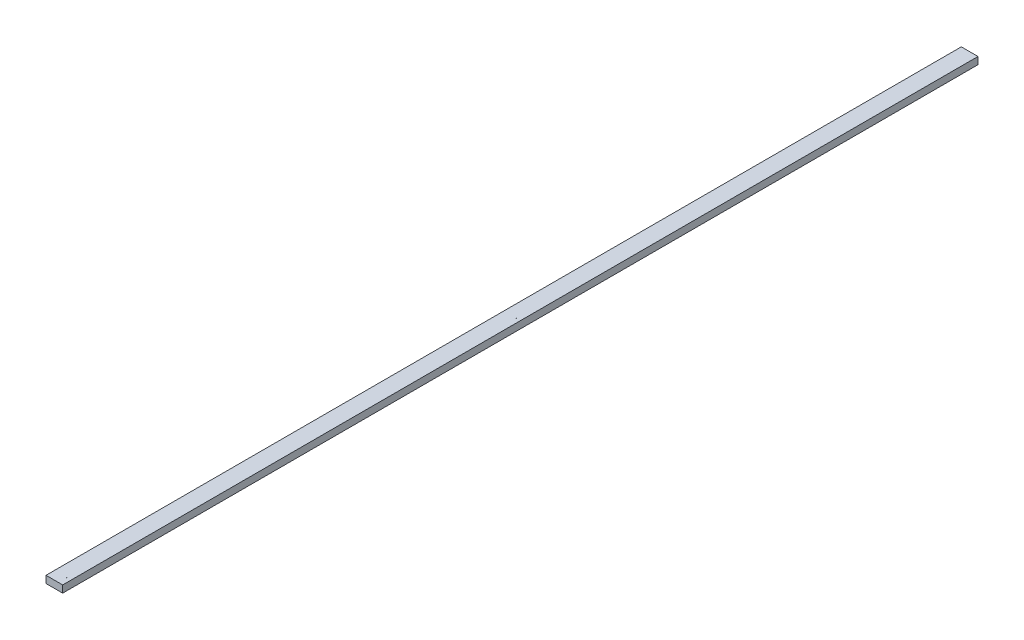
from build123d import *

# Parameters (mm, degrees)
SKETCH1_W           = 88.9
SKETCH1_H           = 38.1
BOSS_EXTRUDE1_DEPTH = 4876.8
SKETCH3_R           = 0.8763
CUT_EXTRUDE2_DEPTH  = 38.1


with BuildPart() as part:
    # Sketch1 → Boss-Extrude1 (new body)
    with BuildSketch(Plane.XY):
        with Locations((44.45, 19.05)):
            Rectangle(SKETCH1_W, SKETCH1_H)
    extrude(amount=BOSS_EXTRUDE1_DEPTH)

    # Sketch3 → Cut-Extrude2 (cut)
    with BuildSketch(Plane(origin=(0, 38.1, 0), x_dir=(1, 0, 0), z_dir=(0, 1, 0))):
        with Locations((66.675, -2438.4)):
            Circle(SKETCH3_R)
        with Locations((22.225, -2438.4)):
            Circle(SKETCH3_R)
        with Locations((66.675, -44.45)):
            Circle(SKETCH3_R)
        with Locations((22.225, -44.45)):
            Circle(SKETCH3_R)
        with Locations((22.225, -4832.35)):
            Circle(SKETCH3_R)
        with Locations((66.675, -4832.35)):
            Circle(SKETCH3_R)
    extrude(amount=-CUT_EXTRUDE2_DEPTH, mode=Mode.SUBTRACT)


solid = part.part
